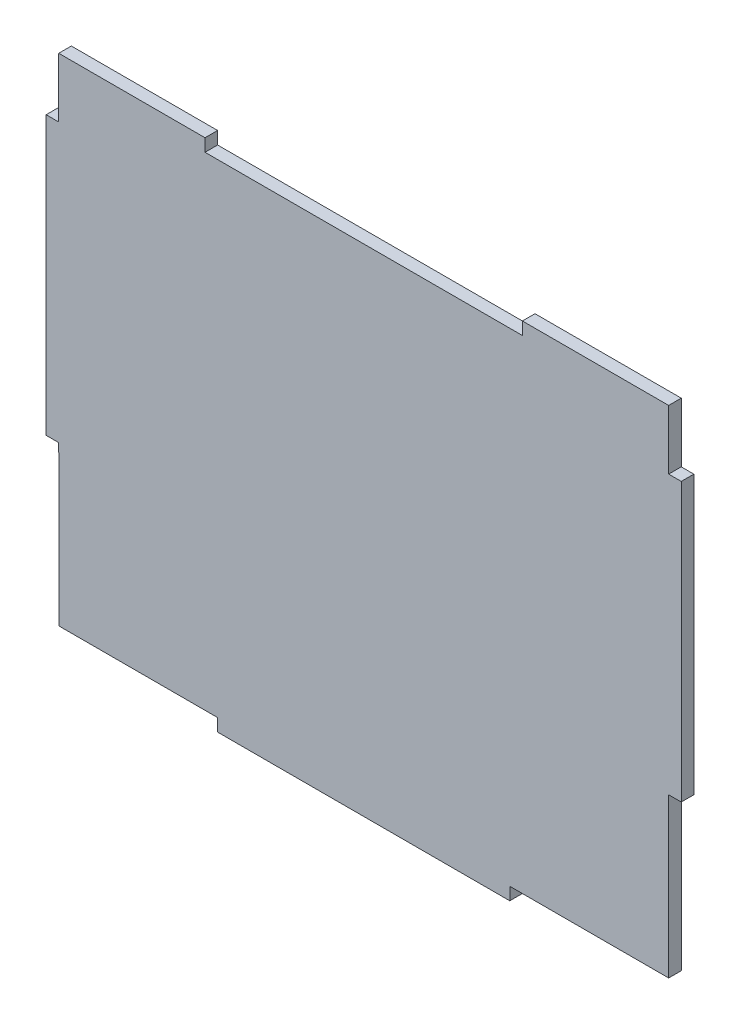
from build123d import *

# Parameters (mm, degrees)
BOSS_EXTRUDE2_DEPTH = 3.175
SKETCH2_W           = 80
SKETCH2_H           = 3.175
CUT_EXTRUDE1_DEPTH  = 4.175


with BuildPart() as part:
    # Sketch1 → Boss-Extrude2 (new body)
    with BuildSketch(Plane.XY):
        Polygon((-76.875, 0), (76.875, 0), (76.875, -15), (80.05, -15), (80.05, -85), (76.875, -85), (76.875, -124.99996875), (36.825, -124.99996875), (36.825, -128.17496875), (-36.825, -128.17496875), (-36.825, -124.99996875), (-76.825, -124.99996875), (-76.875, -85), (-80.05, -85), (-80.05, -15), (-76.875, -15), align=None)
    extrude(amount=BOSS_EXTRUDE2_DEPTH)

    # Sketch2 → Cut-Extrude1 (cut, through all)
    with BuildSketch(Plane.XY.offset(3.175)):
        with Locations((0, -1.5875)):
            Rectangle(SKETCH2_W, SKETCH2_H)
    extrude(amount=-CUT_EXTRUDE1_DEPTH, mode=Mode.SUBTRACT)


solid = part.part
